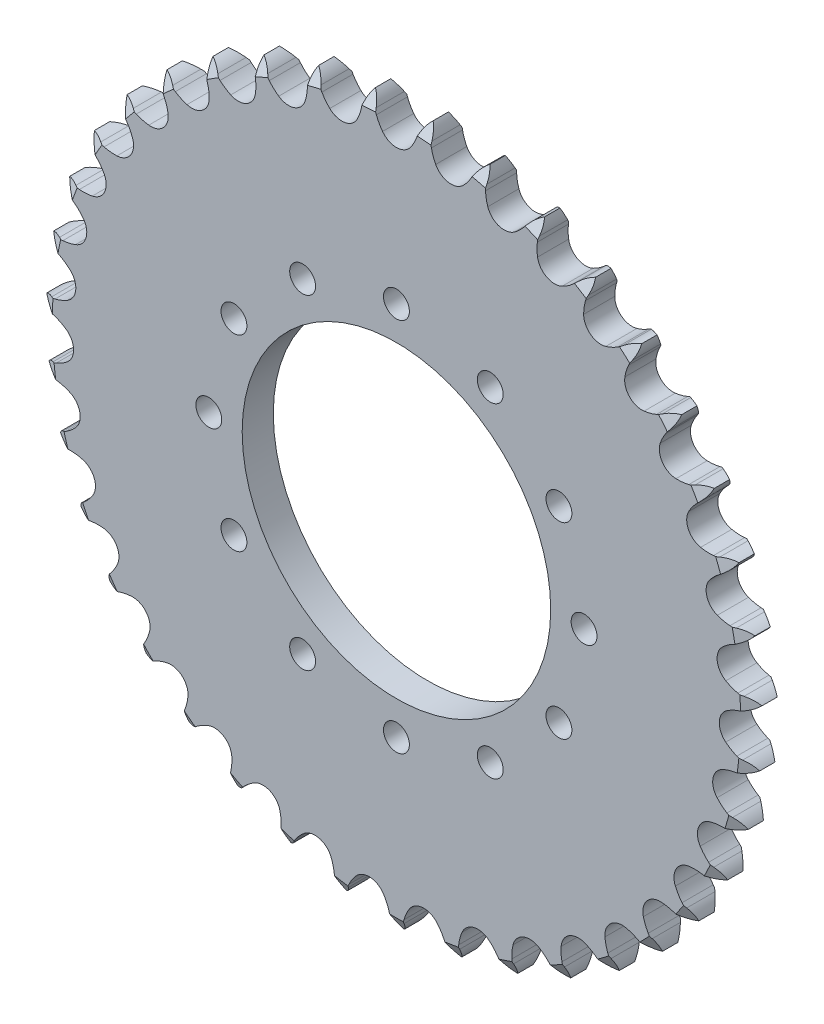
from build123d import *

# Parameters (mm, degrees)
EXTRUSION_DEPTH        = 7.2136
SKETCH1_R              = 35.764294032
CUT_EXTRUDE_DEPTH      = 1
CUT_EXTRUDE_DEPTH_BACK = 8.2136
F_6_0MM_DOWEL_HOLE1_D  = 6
CIRPATTERN1_COUNT      = 12


with BuildPart() as part:
    # Teeth Sketch → Extrusion (new body)
    with BuildSketch(Plane.XY):
        with BuildLine():
            ThreePointArc((6.676484762, 82.703103732), (5.710873677, 81.555589606), (5.037571935, 80.215493266))
            Line((5.037571935, 80.215493266), (4.65053543, 79.150636707))
            ThreePointArc((4.65053543, 79.150636707), (4.030589042, 77.787636082), (3.22092759, 76.5280518))
            ThreePointArc((3.22092759, 76.5280518), (0, 74.905926143), (-3.22092759, 76.5280518))
            ThreePointArc((-3.22092759, 76.5280518), (-4.030589042, 77.787636082), (-4.65053543, 79.150636707))
            Line((-4.65053543, 79.150636707), (-5.037571935, 80.215493266))
            ThreePointArc((-5.037571935, 80.215493266), (-5.710873677, 81.555589606), (-6.676484762, 82.703103732))
            ThreePointArc((-6.676484762, 82.703103732), (-7.445517227, 81.415554702), (-7.895133318, 79.984807062))
            Line((-7.895133318, 79.984807062), (-8.106342797, 78.871655094))
            ThreePointArc((-8.106342797, 78.871655094), (-8.499620367, 77.426858575), (-9.096745387, 76.053706749))
            ThreePointArc((-9.096745387, 76.053706749), (-12.015755556, 73.935914073), (-15.455180235, 75.020360508))
            ThreePointArc((-15.455180235, 75.020360508), (-16.456408311, 76.133754674), (-17.286967233, 77.379658404))
            Line((-17.286967233, 77.379658404), (-17.83980672, 78.368640329))
            ThreePointArc((-17.83980672, 78.368640329), (-18.719355953, 79.583377579), (-19.856536839, 80.561136787))
            ThreePointArc((-19.856536839, 80.561136787), (-20.409073146, 79.166899696), (-20.623358765, 77.682556369))
            Line((-20.623358765, 77.682556369), (-20.653271004, 76.549939044))
            ThreePointArc((-20.653271004, 76.549939044), (-20.809694072, 75.060766102), (-21.178817437, 73.609610642))
            ThreePointArc((-21.178817437, 73.609610642), (-23.720309356, 71.051000665), (-27.289151829, 71.569681286))
            ThreePointArc((-27.289151829, 71.569681286), (-28.456015249, 72.508049011), (-29.475675664, 73.604587595))
            Line((-29.475675664, 73.604587595), (-30.179999883, 74.492080773))
            ThreePointArc((-30.179999883, 74.492080773), (-31.243016742, 75.549997876), (-32.522315041, 76.332678717))
            ThreePointArc((-32.522315041, 76.332678717), (-32.844044791, 74.867863573), (-32.817450053, 73.368368272))
            Line((-32.817450053, 73.368368272), (-32.66529034, 72.245619783))
            ThreePointArc((-32.66529034, 72.245619783), (-32.580807632, 70.750639215), (-32.71236924, 69.259064285))
            ThreePointArc((-32.71236924, 69.259064285), (-34.810519602, 66.325903661), (-38.416348726, 66.265384911))
            ThreePointArc((-38.416348726, 66.265384911), (-39.71862634, 67.004422965), (-40.900979579, 67.923196629))
            Line((-40.900979579, 67.923196629), (-41.738546902, 68.686215454))
            ThreePointArc((-41.738546902, 68.686215454), (-42.957499809, 69.559912912), (-44.345782367, 70.127244363))
            ThreePointArc((-44.345782367, 70.127244363), (-44.428372928, 68.629789109), (-44.161586623, 67.153977974))
            Line((-44.161586623, 67.153977974), (-43.831295815, 66.070176918))
            ThreePointArc((-43.831295815, 66.070176918), (-43.508095388, 64.608107935), (-43.398687863, 63.114744543))
            ThreePointArc((-43.398687863, 63.114744543), (-44.999155676, 59.883000591), (-48.54858237, 59.244849876))
            ThreePointArc((-48.54858237, 59.244849876), (-49.952545871, 59.765417561), (-51.266969607, 60.48263055))
            Line((-51.266969607, 60.48263055), (-52.21608748, 61.101413234))
            ThreePointArc((-52.21608748, 61.101413234), (-53.559406195, 61.768262742), (-55.020717224, 62.105551216))
            ThreePointArc((-55.020717224, 62.105551216), (-54.862029543, 60.614239157), (-54.361961296, 59.200334922))
            Line((-54.361961296, 59.200334922), (-53.862093752, 58.183551176))
            ThreePointArc((-53.862093752, 58.183551176), (-53.308546327, 56.792260597), (-52.961003266, 55.335786069))
            ThreePointArc((-52.961003266, 55.335786069), (-54.022337255, 51.889159262), (-57.423433231, 50.689904348))
            ThreePointArc((-57.423433231, 50.689904348), (-58.892720703, 50.978519235), (-60.305172051, 51.475596109))
            Line((-60.305172051, 51.475596109), (-61.34125882, 51.934116506))
            ThreePointArc((-61.34125882, 51.934116506), (-62.774152094, 52.376847013), (-64.270644405, 52.475356916))
            ThreePointArc((-64.270644405, 52.475356916), (-63.87478841, 51.02881225), (-63.154389727, 49.713434291))
            Line((-63.154389727, 49.713434291), (-62.497891753, 48.790002021))
            ThreePointArc((-62.497891753, 48.790002021), (-61.728333918, 47.505523541), (-61.151656504, 46.123659804))
            ThreePointArc((-61.151656504, 46.123659804), (-61.646368676, 42.551415963), (-64.811047336, 40.822116924))
            ThreePointArc((-64.811047336, 40.822116924), (-66.307605004, 40.871304038), (-67.781502216, 41.135370767))
            Line((-67.781502216, 41.135370767), (-68.877723777, 41.42175344))
            ThreePointArc((-68.877723777, 41.42175344), (-70.363080428, 41.628898458), (-71.855995657, 41.486078435))
            ThreePointArc((-71.855995657, 41.486078435), (-71.23322381, 40.12176591), (-70.311152637, 38.938981826))
            Line((-70.311152637, 38.938981826), (-69.515027187, 38.132817442))
            ThreePointArc((-69.515027187, 38.132817442), (-68.549390085, 36.988418379), (-67.75851396, 35.716954977))
            ThreePointArc((-67.75851396, 35.716954977), (-67.673791529, 32.111613343), (-70.520089358, 29.897058114))
            ThreePointArc((-70.520089358, 29.897058114), (-72.005157166, 29.705543536), (-73.502327078, 29.729760931))
            Line((-73.502327078, 29.729760931), (-74.630291869, 29.836588719))
            ThreePointArc((-74.630291869, 29.836588719), (-76.129641939, 29.8027833), (-77.580314364, 29.422332315))
            ThreePointArc((-77.580314364, 29.422332315), (-76.74675613, 28.175586908), (-75.646893627, 27.156030185))
            Line((-75.646893627, 27.156030185), (-74.731759931, 26.488012922))
            ThreePointArc((-74.731759931, 26.488012922), (-73.595053056, 25.51333261), (-72.610461496, 24.385199777))
            ThreePointArc((-72.610461496, 24.385199777), (-71.948498729, 20.840136804), (-74.402698108, 18.197681204))
            ThreePointArc((-74.402698108, 18.197681204), (-75.837813579, 17.77042506), (-77.319480277, 17.554165902))
            Line((-77.319480277, 17.554165902), (-78.449974603, 17.478672021))
            ThreePointArc((-78.449974603, 17.478672021), (-79.924485713, 17.204791709), (-81.295343681, 16.596563242))
            ThreePointArc((-81.295343681, 16.596563242), (-80.27258778, 15.499675005), (-79.023419807, 14.669751627))
            Line((-79.023419807, 14.669751627), (-78.012979347, 14.15718278))
            ThreePointArc((-78.012979347, 14.15718278), (-76.734642811, 13.377464928), (-75.58183622, 12.421880712))
            ThreePointArc((-75.58183622, 12.421880712), (-74.359777605, 9.028911669), (-76.358316059, 6.026993909))
            ThreePointArc((-76.358316059, 6.026993909), (-77.706310456, 5.375061909), (-79.134099551, 4.923927198))
            Line((-79.134099551, 4.923927198), (-80.237844202, 4.6680669))
            ThreePointArc((-80.237844202, 4.6680669), (-81.649327289, 4.161205049), (-82.904866299, 3.340951899))
            ThreePointArc((-82.904866299, 3.340951899), (-81.719401571, 2.422329661), (-80.353280924, 1.803534207))
            Line((-80.353280924, 1.803534207), (-79.273703577, 1.45968904))
            ThreePointArc((-79.273703577, 1.45968904), (-77.886845624, 0.895127931), (-76.595681088, 0.136841462))
            ThreePointArc((-76.595681088, 0.136841462), (-74.8451773, -3.016157536), (-76.336293733, -6.299789363))
            ThreePointArc((-76.336293733, -6.299789363), (-77.56225471, -7.159512522), (-78.899187214, -7.833838635))
            Line((-78.899187214, -7.833838635), (-79.947595784, -8.263438702))
            ThreePointArc((-79.947595784, -8.263438702), (-81.259494176, -8.990154635), (-82.367196428, -10.001188343))
            ThreePointArc((-82.367196428, -10.001188343), (-81.049725787, -10.717752749), (-79.602034272, -11.109393802))
            Line((-79.602034272, -11.109393802), (-78.481280524, -11.275609878))
            ThreePointArc((-78.481280524, -11.275609878), (-77.021820047, -11.610392409), (-75.625738049, -12.151741911))
            ThreePointArc((-75.625738049, -12.151741911), (-73.392126218, -14.983109845), (-74.337201497, -18.463411399))
            ThreePointArc((-74.337201497, -18.463411399), (-75.409377308, -19.50865934), (-76.620827372, -20.388712162))
            Line((-76.620827372, -20.388712162), (-77.586746629, -20.980925582))
            ThreePointArc((-77.586746629, -20.980925582), (-78.765082849, -21.908674036), (-79.696259435, -23.08430306))
            ThreePointArc((-79.696259435, -23.08430306), (-78.280904679, -23.580250992), (-76.789136745, -23.734594346))
            Line((-76.789136745, -23.734594346), (-75.656233531, -23.718876424))
            ThreePointArc((-75.656233531, -23.718876424), (-74.161969788, -23.815209685), (-72.697128119, -24.125601551))
            ThreePointArc((-72.697128119, -24.125601551), (-70.038257617, -26.562007479), (-70.41281479, -30.148840778))
            ThreePointArc((-70.41281479, -30.148840778), (-71.303436645, -31.352542128), (-72.358028349, -32.415528753))
            Line((-72.358028349, -32.415528753), (-73.216441492, -33.155017511))
            ThreePointArc((-73.216441492, -33.155017511), (-74.230697248, -34.259770288), (-74.961231185, -35.569546454))
            ThreePointArc((-74.961231185, -35.569546454), (-73.484649258, -35.832033121), (-71.987440912, -35.745081364))
            Line((-71.987440912, -35.745081364), (-70.871729829, -35.547836529))
            ThreePointArc((-70.871729829, -35.547836529), (-69.381363468, -35.403225539), (-67.885700756, -35.474620783))
            ThreePointArc((-67.885700756, -35.474620783), (-64.870434934, -37.452963072), (-64.664773166, -41.053431017))
            ThreePointArc((-64.664773166, -41.053431017), (-65.350774426, -42.384410543), (-66.221194398, -43.602800177))
            Line((-66.221194398, -43.602800177), (-66.949868978, -44.470411902))
            ThreePointArc((-66.949868978, -44.470411902), (-67.773775581, -45.723556485), (-68.284746423, -47.133557278))
            ThreePointArc((-68.284746423, -47.133557278), (-66.785180021, -47.155784414), (-65.321308173, -46.829789551))
            Line((-65.321308173, -46.829789551), (-64.251685552, -46.456126341))
            ThreePointArc((-64.251685552, -46.456126341), (-62.803816278, -46.074316448), (-61.316069403, -45.904865971))
            ThreePointArc((-61.316069403, -45.904865971), (-58.022502061, -47.373906594), (-57.241947884, -50.894758957))
            ThreePointArc((-57.241947884, -50.894758957), (-57.705561477, -52.318544989), (-58.369266298, -53.66078198))
            Line((-58.369266298, -53.66078198), (-58.949330025, -54.634045983))
            ThreePointArc((-58.949330025, -54.634045983), (-59.561548726, -56.003126587), (-59.839722596, -57.476833727))
            ThreePointArc((-59.839722596, -57.476833727), (-58.356009703, -57.25822566), (-56.963387864, -56.701630787))
            Line((-56.963387864, -56.701630787), (-55.967556369, -56.161226883))
            ThreePointArc((-55.967556369, -56.161226883), (-54.599683236, -55.552106762), (-53.15838406, -55.146199243))
            ThreePointArc((-53.15838406, -55.146199243), (-49.671816862, -56.06789082), (-48.336586219, -59.417939375))
            ThreePointArc((-48.336586219, -59.417939375), (-48.565804798, -60.897656602), (-49.00560486, -62.328977716))
            Line((-49.00560486, -62.328977716), (-49.422034389, -63.382686971))
            ThreePointArc((-49.422034389, -63.382686971), (-49.806709045, -64.832245127), (-49.844881387, -66.331490374))
            ThreePointArc((-49.844881387, -66.331490374), (-48.415449386, -65.877708938), (-47.130145731, -65.104929569))
            Line((-47.130145731, -65.104929569), (-46.233896874, -64.411781148))
            ThreePointArc((-46.233896874, -64.411781148), (-44.981447078, -63.591126692), (-43.623924493, -62.959274922))
            ThreePointArc((-43.623924493, -62.959274922), (-40.034657698, -63.309746125), (-38.179332362, -66.402226373))
            ThreePointArc((-38.179332362, -66.402226373), (-38.168219284, -67.899550896), (-38.372723998, -69.38288567))
            Line((-38.372723998, -69.38288567), (-38.614734022, -70.489749661))
            ThreePointArc((-38.614734022, -70.489749661), (-38.761901763, -71.982242573), (-38.559083932, -73.468196262))
            ThreePointArc((-38.559083932, -73.468196262), (-37.220954361, -72.790994159), (-36.076257579, -71.822044874))
            Line((-36.076257579, -71.822044874), (-35.302803736, -70.994104116))
            ThreePointArc((-35.302803736, -70.994104116), (-34.198215068, -69.983169844), (-32.959628196, -69.141738451))
            ThreePointArc((-32.959628196, -69.141738451), (-29.360621929, -68.91191226), (-27.033253851, -71.666730588))
            ThreePointArc((-27.033253851, -71.666730588), (-26.78209694, -73.142882488), (-26.74600974, -74.639813329))
            Line((-26.74600974, -74.639813329), (-26.807332328, -75.77116486))
            ThreePointArc((-26.807332328, -75.77116486), (-26.713181585, -77.267937748), (-26.274626458, -78.702114459))
            ThreePointArc((-26.274626458, -78.702114459), (-25.06245617, -77.819030866), (-24.088013307, -76.679006943))
            Line((-24.088013307, -76.679006943), (-23.457386525, -75.737717079))
            ThreePointArc((-23.457386525, -75.737717079), (-22.529267252, -74.562685657), (-21.441694841, -73.533467273))
            ThreePointArc((-21.441694841, -73.533467273), (-17.926161474, -72.729296065), (-15.187028265, -75.075104125))
            ThreePointArc((-15.187028265, -75.075104125), (-14.702332353, -76.491851845), (-14.426587879, -77.96360903))
            Line((-14.426587879, -77.96360903), (-14.305634807, -79.090146691))
            ThreePointArc((-14.305634807, -79.090146691), (-13.972604036, -80.552433921), (-13.309669959, -81.897689231))
            ThreePointArc((-13.309669959, -81.897689231), (-12.254853529, -80.83159555), (-11.475902142, -79.55002301))
            Line((-11.475902142, -79.55002301), (-11.004435324, -78.519762952))
            ThreePointArc((-11.004435324, -78.519762952), (-10.276823247, -77.211067077), (-9.368432854, -76.020717918))
            ThreePointArc((-9.368432854, -76.020717918), (-6.027422853, -74.663029306), (-2.947466624, -76.5390719))
            ThreePointArc((-2.947466624, -76.5390719), (-2.241785081, -77.859722417), (-1.733524971, -79.26818821))
            Line((-1.733524971, -79.26818821), (-1.43342886, -80.360735266))
            ThreePointArc((-1.43342886, -80.360735266), (-0.870143382, -81.750664368), (0, -82.97215687))
            ThreePointArc((0, -82.97215687), (0.870143382, -81.750664368), (1.43342886, -80.360735266))
            Line((1.43342886, -80.360735266), (1.733524971, -79.26818821))
            ThreePointArc((1.733524971, -79.26818821), (2.241785081, -77.859722417), (2.947466624, -76.5390719))
            ThreePointArc((2.947466624, -76.5390719), (6.027422853, -74.663029306), (9.368432854, -76.020717918))
            ThreePointArc((9.368432854, -76.020717918), (10.276823247, -77.211067077), (11.004435324, -78.519762952))
            Line((11.004435324, -78.519762952), (11.475902142, -79.55002301))
            ThreePointArc((11.475902142, -79.55002301), (12.254853529, -80.83159555), (13.309669959, -81.897689231))
            ThreePointArc((13.309669959, -81.897689231), (13.972604036, -80.552433921), (14.305634807, -79.090146691))
            Line((14.305634807, -79.090146691), (14.426587879, -77.96360903))
            ThreePointArc((14.426587879, -77.96360903), (14.702332353, -76.491851845), (15.187028265, -75.075104125))
            ThreePointArc((15.187028265, -75.075104125), (17.926161474, -72.729296065), (21.441694841, -73.533467273))
            ThreePointArc((21.441694841, -73.533467273), (22.529267252, -74.562685657), (23.457386525, -75.737717079))
            Line((23.457386525, -75.737717079), (24.088013307, -76.679006943))
            ThreePointArc((24.088013307, -76.679006943), (25.06245617, -77.819030866), (26.274626458, -78.702114459))
            ThreePointArc((26.274626458, -78.702114459), (26.713181585, -77.267937748), (26.807332328, -75.77116486))
            Line((26.807332328, -75.77116486), (26.74600974, -74.639813329))
            ThreePointArc((26.74600974, -74.639813329), (26.78209694, -73.142882488), (27.033253851, -71.666730588))
            ThreePointArc((27.033253851, -71.666730588), (29.360621929, -68.91191226), (32.959628196, -69.141738451))
            ThreePointArc((32.959628196, -69.141738451), (34.198215068, -69.983169844), (35.302803736, -70.994104116))
            Line((35.302803736, -70.994104116), (36.076257579, -71.822044874))
            ThreePointArc((36.076257579, -71.822044874), (37.220954361, -72.790994159), (38.559083932, -73.468196262))
            ThreePointArc((38.559083932, -73.468196262), (38.761901763, -71.982242573), (38.614734022, -70.489749661))
            Line((38.614734022, -70.489749661), (38.372723998, -69.38288567))
            ThreePointArc((38.372723998, -69.38288567), (38.168219284, -67.899550896), (38.179332362, -66.402226373))
            ThreePointArc((38.179332362, -66.402226373), (40.034657698, -63.309746125), (43.623924493, -62.959274922))
            ThreePointArc((43.623924493, -62.959274922), (44.981447078, -63.591126692), (46.233896874, -64.411781148))
            Line((46.233896874, -64.411781148), (47.130145731, -65.104929569))
            ThreePointArc((47.130145731, -65.104929569), (48.415449386, -65.877708938), (49.844881387, -66.331490374))
            ThreePointArc((49.844881387, -66.331490374), (49.806709045, -64.832245127), (49.422034389, -63.382686971))
            Line((49.422034389, -63.382686971), (49.00560486, -62.328977716))
            ThreePointArc((49.00560486, -62.328977716), (48.565804798, -60.897656602), (48.336586219, -59.417939375))
            ThreePointArc((48.336586219, -59.417939375), (49.671816862, -56.06789082), (53.15838406, -55.146199243))
            ThreePointArc((53.15838406, -55.146199243), (54.599683236, -55.552106762), (55.967556369, -56.161226883))
            Line((55.967556369, -56.161226883), (56.963387864, -56.701630787))
            ThreePointArc((56.963387864, -56.701630787), (58.356009703, -57.25822566), (59.839722596, -57.476833727))
            ThreePointArc((59.839722596, -57.476833727), (59.561548726, -56.003126587), (58.949330025, -54.634045983))
            Line((58.949330025, -54.634045983), (58.369266298, -53.66078198))
            ThreePointArc((58.369266298, -53.66078198), (57.705561477, -52.318544989), (57.241947884, -50.894758957))
            ThreePointArc((57.241947884, -50.894758957), (58.022502061, -47.373906594), (61.316069403, -45.904865971))
            ThreePointArc((61.316069403, -45.904865971), (62.803816278, -46.074316448), (64.251685552, -46.456126341))
            Line((64.251685552, -46.456126341), (65.321308173, -46.829789551))
            ThreePointArc((65.321308173, -46.829789551), (66.785180021, -47.155784414), (68.284746423, -47.133557278))
            ThreePointArc((68.284746423, -47.133557278), (67.773775581, -45.723556485), (66.949868978, -44.470411902))
            Line((66.949868978, -44.470411902), (66.221194398, -43.602800177))
            ThreePointArc((66.221194398, -43.602800177), (65.350774426, -42.384410543), (64.664773166, -41.053431017))
            ThreePointArc((64.664773166, -41.053431017), (64.870434934, -37.452963072), (67.885700756, -35.474620783))
            ThreePointArc((67.885700756, -35.474620783), (69.381363468, -35.403225539), (70.871729829, -35.547836529))
            Line((70.871729829, -35.547836529), (71.987440912, -35.745081364))
            ThreePointArc((71.987440912, -35.745081364), (73.484649258, -35.832033121), (74.961231185, -35.569546454))
            ThreePointArc((74.961231185, -35.569546454), (74.230697248, -34.259770288), (73.216441492, -33.155017511))
            Line((73.216441492, -33.155017511), (72.358028349, -32.415528753))
            ThreePointArc((72.358028349, -32.415528753), (71.303436645, -31.352542128), (70.41281479, -30.148840778))
            ThreePointArc((70.41281479, -30.148840778), (70.038257617, -26.562007479), (72.697128119, -24.125601551))
            ThreePointArc((72.697128119, -24.125601551), (74.161969788, -23.815209685), (75.656233531, -23.718876424))
            Line((75.656233531, -23.718876424), (76.789136745, -23.734594346))
            ThreePointArc((76.789136745, -23.734594346), (78.280904679, -23.580250992), (79.696259435, -23.08430306))
            ThreePointArc((79.696259435, -23.08430306), (78.765082849, -21.908674036), (77.586746629, -20.980925582))
            Line((77.586746629, -20.980925582), (76.620827372, -20.388712162))
            ThreePointArc((76.620827372, -20.388712162), (75.409377308, -19.50865934), (74.337201497, -18.463411399))
            ThreePointArc((74.337201497, -18.463411399), (73.392126218, -14.983109845), (75.625738049, -12.151741911))
            ThreePointArc((75.625738049, -12.151741911), (77.021820047, -11.610392409), (78.481280524, -11.275609878))
            Line((78.481280524, -11.275609878), (79.602034272, -11.109393802))
            ThreePointArc((79.602034272, -11.109393802), (81.049725787, -10.717752749), (82.367196428, -10.001188343))
            ThreePointArc((82.367196428, -10.001188343), (81.259494176, -8.990154635), (79.947595784, -8.263438702))
            Line((79.947595784, -8.263438702), (78.899187214, -7.833838635))
            ThreePointArc((78.899187214, -7.833838635), (77.56225471, -7.159512522), (76.336293733, -6.299789363))
            ThreePointArc((76.336293733, -6.299789363), (74.8451773, -3.016157536), (76.595681088, 0.136841462))
            ThreePointArc((76.595681088, 0.136841462), (77.886845624, 0.895127931), (79.273703577, 1.45968904))
            Line((79.273703577, 1.45968904), (80.353280924, 1.803534207))
            ThreePointArc((80.353280924, 1.803534207), (81.719401571, 2.422329661), (82.904866299, 3.340951899))
            ThreePointArc((82.904866299, 3.340951899), (81.649327289, 4.161205049), (80.237844202, 4.6680669))
            Line((80.237844202, 4.6680669), (79.134099551, 4.923927198))
            ThreePointArc((79.134099551, 4.923927198), (77.706310456, 5.375061909), (76.358316059, 6.026993909))
            ThreePointArc((76.358316059, 6.026993909), (74.359777605, 9.028911669), (75.58183622, 12.421880712))
            ThreePointArc((75.58183622, 12.421880712), (76.734642811, 13.377464928), (78.012979347, 14.15718278))
            Line((78.012979347, 14.15718278), (79.023419807, 14.669751627))
            ThreePointArc((79.023419807, 14.669751627), (80.27258778, 15.499675005), (81.295343681, 16.596563242))
            ThreePointArc((81.295343681, 16.596563242), (79.924485713, 17.204791709), (78.449974603, 17.478672021))
            Line((78.449974603, 17.478672021), (77.319480277, 17.554165902))
            ThreePointArc((77.319480277, 17.554165902), (75.837813579, 17.77042506), (74.402698108, 18.197681204))
            ThreePointArc((74.402698108, 18.197681204), (71.948498729, 20.840136804), (72.610461496, 24.385199777))
            ThreePointArc((72.610461496, 24.385199777), (73.595053056, 25.51333261), (74.731759931, 26.488012922))
            Line((74.731759931, 26.488012922), (75.646893627, 27.156030185))
            ThreePointArc((75.646893627, 27.156030185), (76.74675613, 28.175586908), (77.580314364, 29.422332315))
            ThreePointArc((77.580314364, 29.422332315), (76.129641939, 29.8027833), (74.630291869, 29.836588719))
            Line((74.630291869, 29.836588719), (73.502327078, 29.729760931))
            ThreePointArc((73.502327078, 29.729760931), (72.005157166, 29.705543536), (70.520089358, 29.897058114))
            ThreePointArc((70.520089358, 29.897058114), (67.673791529, 32.111613343), (67.75851396, 35.716954977))
            ThreePointArc((67.75851396, 35.716954977), (68.549390085, 36.988418379), (69.515027187, 38.132817442))
            Line((69.515027187, 38.132817442), (70.311152637, 38.938981826))
            ThreePointArc((70.311152637, 38.938981826), (71.23322381, 40.12176591), (71.855995657, 41.486078435))
            ThreePointArc((71.855995657, 41.486078435), (70.363080428, 41.628898458), (68.877723777, 41.42175344))
            Line((68.877723777, 41.42175344), (67.781502216, 41.135370767))
            ThreePointArc((67.781502216, 41.135370767), (66.307605004, 40.871304038), (64.811047336, 40.822116924))
            ThreePointArc((64.811047336, 40.822116924), (61.646368676, 42.551415963), (61.151656504, 46.123659804))
            ThreePointArc((61.151656504, 46.123659804), (61.728333918, 47.505523541), (62.497891753, 48.790002021))
            Line((62.497891753, 48.790002021), (63.154389727, 49.713434291))
            ThreePointArc((63.154389727, 49.713434291), (63.87478841, 51.02881225), (64.270644405, 52.475356916))
            ThreePointArc((64.270644405, 52.475356916), (62.774152094, 52.376847013), (61.34125882, 51.934116506))
            Line((61.34125882, 51.934116506), (60.305172051, 51.475596109))
            ThreePointArc((60.305172051, 51.475596109), (58.892720703, 50.978519235), (57.423433231, 50.689904348))
            ThreePointArc((57.423433231, 50.689904348), (54.022337255, 51.889159262), (52.961003266, 55.335786069))
            ThreePointArc((52.961003266, 55.335786069), (53.308546327, 56.792260597), (53.862093752, 58.183551176))
            Line((53.862093752, 58.183551176), (54.361961296, 59.200334922))
            ThreePointArc((54.361961296, 59.200334922), (54.862029543, 60.614239157), (55.020717224, 62.105551216))
            ThreePointArc((55.020717224, 62.105551216), (53.559406195, 61.768262742), (52.21608748, 61.101413234))
            Line((52.21608748, 61.101413234), (51.266969607, 60.48263055))
            ThreePointArc((51.266969607, 60.48263055), (49.952545871, 59.765417561), (48.54858237, 59.244849876))
            ThreePointArc((48.54858237, 59.244849876), (44.999155676, 59.883000591), (43.398687863, 63.114744543))
            ThreePointArc((43.398687863, 63.114744543), (43.508095388, 64.608107935), (43.831295815, 66.070176918))
            Line((43.831295815, 66.070176918), (44.161586623, 67.153977974))
            ThreePointArc((44.161586623, 67.153977974), (44.428372928, 68.629789109), (44.345782367, 70.127244363))
            ThreePointArc((44.345782367, 70.127244363), (42.957499809, 69.559912912), (41.738546902, 68.686215454))
            Line((41.738546902, 68.686215454), (40.900979579, 67.923196629))
            ThreePointArc((40.900979579, 67.923196629), (39.71862634, 67.004422965), (38.416348726, 66.265384911))
            ThreePointArc((38.416348726, 66.265384911), (34.810519602, 66.325903661), (32.71236924, 69.259064285))
            ThreePointArc((32.71236924, 69.259064285), (32.580807632, 70.750639215), (32.66529034, 72.245619783))
            Line((32.66529034, 72.245619783), (32.817450053, 73.368368272))
            ThreePointArc((32.817450053, 73.368368272), (32.844044791, 74.867863573), (32.522315041, 76.332678717))
            ThreePointArc((32.522315041, 76.332678717), (31.243016742, 75.549997876), (30.179999883, 74.492080773))
            Line((30.179999883, 74.492080773), (29.475675664, 73.604587595))
            ThreePointArc((29.475675664, 73.604587595), (28.456015249, 72.508049011), (27.289151829, 71.569681286))
            ThreePointArc((27.289151829, 71.569681286), (23.720309356, 71.051000665), (21.178817437, 73.609610642))
            ThreePointArc((21.178817437, 73.609610642), (20.809694072, 75.060766102), (20.653271004, 76.549939044))
            Line((20.653271004, 76.549939044), (20.623358765, 77.682556369))
            ThreePointArc((20.623358765, 77.682556369), (20.409073146, 79.166899696), (19.856536839, 80.561136787))
            ThreePointArc((19.856536839, 80.561136787), (18.719355953, 79.583377579), (17.83980672, 78.368640329))
            Line((17.83980672, 78.368640329), (17.286967233, 77.379658404))
            ThreePointArc((17.286967233, 77.379658404), (16.456408311, 76.133754674), (15.455180235, 75.020360508))
            ThreePointArc((15.455180235, 75.020360508), (12.015755556, 73.935914073), (9.096745387, 76.053706749))
            ThreePointArc((9.096745387, 76.053706749), (8.499620367, 77.426858575), (8.106342797, 78.871655094))
            Line((8.106342797, 78.871655094), (7.895133318, 79.984807062))
            ThreePointArc((7.895133318, 79.984807062), (7.445517227, 81.415554702), (6.676484762, 82.703103732))
        make_face()
    extrude(amount=EXTRUSION_DEPTH)

    # Sketch1 → Cut-Extrude (cut, two sides)
    with BuildSketch(Plane(origin=(0, 0, 0), x_dir=(-1, 0, 0), z_dir=(0, 0, -1))) as cut_extrude_sk:
        Circle(SKETCH1_R)
    extrude(amount=CUT_EXTRUDE_DEPTH, mode=Mode.SUBTRACT)
    extrude(cut_extrude_sk.sketch, amount=-CUT_EXTRUDE_DEPTH_BACK, mode=Mode.SUBTRACT)

    # Ø6.0mm Dowel Hole1 (through all)
    with Locations(Plane.XY.offset(7.2136)):
        with Locations((-43.500000122, 0)):
            f_6_0mm_dowel_hole1 = Hole(F_6_0MM_DOWEL_HOLE1_D / 2)

    # CirPattern1: Ø6.0mm Dowel Hole1 ×12 about axis
    cirpattern1_axis = Axis((0, 0, 0), (0, 0, 1))
    for i in range(1, CIRPATTERN1_COUNT):
        add(f_6_0mm_dowel_hole1.rotate(cirpattern1_axis, i * 360 / CIRPATTERN1_COUNT), mode=Mode.SUBTRACT)

    # Sketch5 → Cut-Revolve1 (revolve, cut)
    with BuildSketch(Plane(origin=(0, 0, 0), x_dir=(0, 0, -1), z_dir=(1, 0, 0))):
        Polygon((-5.3848, -82.97215687), (-7.2136, -79.778574738), (-7.2136, -82.97215687), align=None)
    cut_revolve1 = revolve(axis=Axis((0, 0, 7.2136), (0, 0, -1)), mode=Mode.SUBTRACT)

    # Mirror1: Cut-Revolve1 across plane
    add(cut_revolve1.mirror(Plane.XY.offset(3.6068)), mode=Mode.SUBTRACT)


solid = part.part
